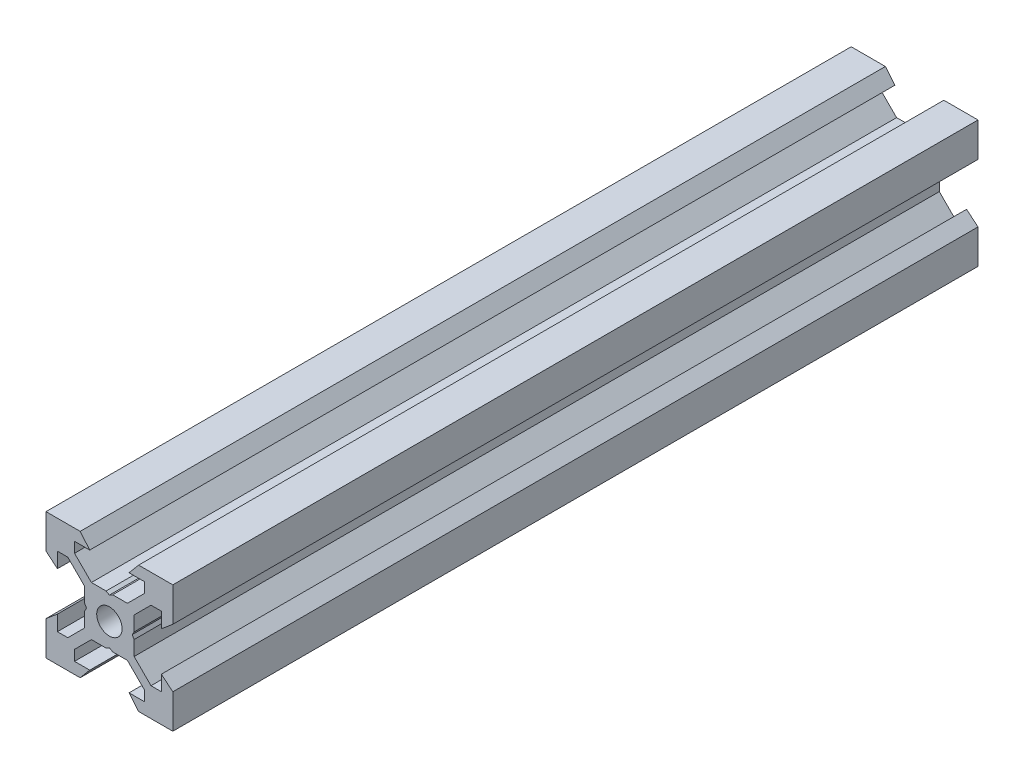
from build123d import *

# Parameters (mm, degrees)
SKETCH1_R           = 2
BOSS_EXTRUDE1_DEPTH = 63.5


with BuildPart() as part:
    # Sketch1 → Boss-Extrude1 (new body, symmetric)
    with BuildSketch(Plane.XY):
        Polygon((10, 10), (10, 4.610379336), (8.2, 3.1), (8.2, 5.5), (6.560660172, 5.5), (3.9, 2.839339828), (3.9, 0.519615242), (3.6, 0), (3.9, -0.519615242), (3.9, -2.839339828), (6.560660172, -5.5), (8.2, -5.5), (8.2, -3.1), (10, -4.610379336), (10, -10), (4.610379336, -10), (3.1, -8.2), (5.5, -8.2), (5.5, -6.560660172), (2.839339828, -3.9), (0.519615242, -3.9), (0, -3.6), (-0.519615242, -3.9), (-2.839339828, -3.9), (-5.5, -6.560660172), (-5.5, -8.2), (-3.1, -8.2), (-4.610379336, -10), (-10, -10), (-10, -4.610379336), (-8.2, -3.1), (-8.2, -5.5), (-6.560660172, -5.5), (-3.9, -2.839339828), (-3.9, -0.519615242), (-3.6, 0), (-3.9, 0.519615242), (-3.9, 2.839339828), (-6.560660172, 5.5), (-8.2, 5.5), (-8.2, 3.1), (-10, 4.610379336), (-10, 10), (-4.610379336, 10), (-3.1, 8.2), (-5.5, 8.2), (-5.5, 6.560660172), (-2.839339828, 3.9), (-0.519615242, 3.9), (0, 3.6), (0.519615242, 3.9), (2.839339828, 3.9), (5.5, 6.560660172), (5.5, 8.2), (3.1, 8.2), (4.610379336, 10), align=None)
        Circle(SKETCH1_R, mode=Mode.SUBTRACT)
    extrude(amount=BOSS_EXTRUDE1_DEPTH, both=True)


solid = part.part
